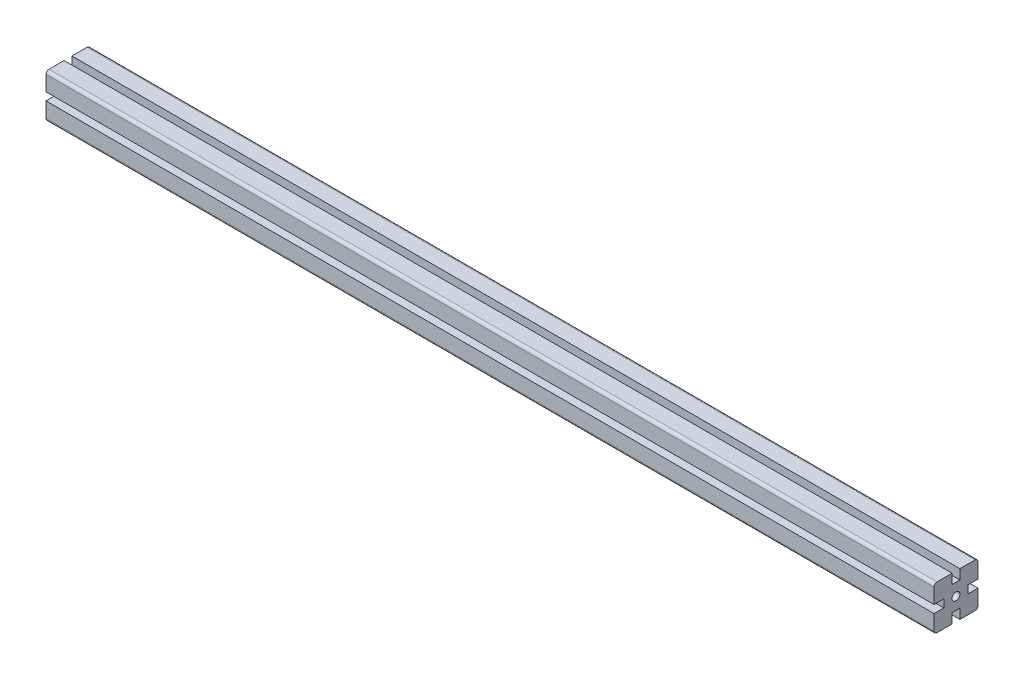
from build123d import *

# Parameters (mm, degrees)
ESQUISSE1_R        = 4
BOSS_EXTRU_1_DEPTH = 908
FILLET1_R          = 3


with BuildPart() as part:
    # Esquisse1 → Boss.-Extru.1 (new body)
    with BuildSketch(Plane(origin=(1000, 0, 0), x_dir=(0, 0, -1), z_dir=(1, 0, 0))):
        Polygon((22.5, -4), (12.5, -4), (12.5, 4), (22.5, 4), (22.5, 22.5), (4, 22.5), (4, 12.5), (-4, 12.5), (-4, 22.5), (-22.5, 22.5), (-22.5, 4), (-12.5, 4), (-12.5, -4), (-22.5, -4), (-22.5, -22.5), (-4, -22.5), (-4, -12.5), (4, -12.5), (4, -22.5), (22.5, -22.5), align=None)
        Circle(ESQUISSE1_R, mode=Mode.SUBTRACT)
    extrude(amount=-BOSS_EXTRU_1_DEPTH)

    # Fillet1
    fillet1_edges = [part.edges().sort_by_distance(p)[0] for p in [
        (546, -22.5, -22.5),
        (546, -22.5, 22.5),
        (546, 22.5, 22.5),
        (546, 22.5, -22.5),
    ]]
    fillet(fillet1_edges, radius=FILLET1_R)


solid = part.part
